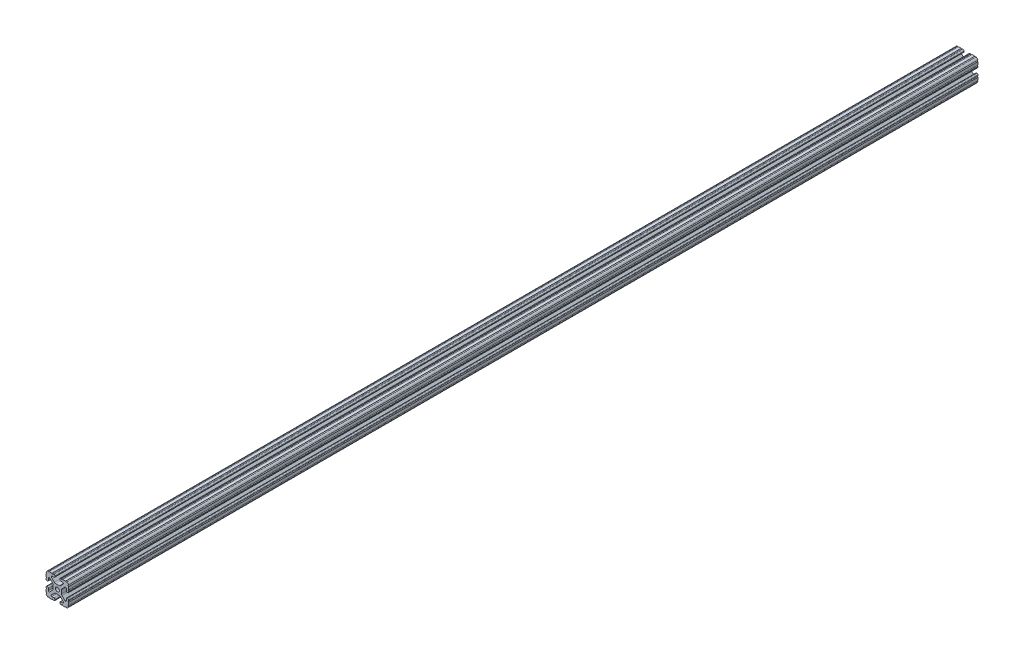
from build123d import *

# Parameters (mm, degrees)
BOSS_EXTRUDE1_DEPTH     = 762
SKETCH5_R               = 1.016
CUT_EXTRUDE1_DEPTH      = 763
CUT_EXTRUDE1_DEPTH_BACK = 763


with BuildPart() as part:
    # Sketch4 → Boss-Extrude1 (new body, symmetric)
    with BuildSketch(Plane.XY):
        with BuildLine():
            Line((5.7912, -19.05), (14.3002, -19.05))
            ThreePointArc((14.3002, -19.05), (17.658815789, -17.658815789), (19.05, -14.3002))
            Line((19.05, -14.3002), (19.05, -5.7912))
            ThreePointArc((19.05, -5.7912), (18.544114832, -4.569885168), (17.3228, -4.064))
            Line((17.3228, -4.064), (16.7132, -4.064))
            ThreePointArc((16.7132, -4.064), (15.491885168, -4.569885168), (14.986, -5.7912))
            Line((14.986, -5.7912), (14.986, -8.996305235))
            ThreePointArc((14.986, -8.996305235), (14.189232738, -10.188751711), (12.782646215, -9.908964256))
            Line((12.782646215, -9.908964256), (7.888897763, -5.015215804))
            ThreePointArc((7.888897763, -5.015215804), (7.219915375, -4.014012907), (6.985, -2.833013566))
            Line((6.985, -2.833013566), (6.985, 0))
            Line((6.985, 0), (3.3274, 0))
            ThreePointArc((3.3274, 0), (2.352827104, -2.352827104), (0, -3.3274))
            Line((0, -3.3274), (0, -6.985))
            Line((0, -6.985), (2.833013566, -6.985))
            ThreePointArc((2.833013566, -6.985), (4.014012907, -7.219915375), (5.015215804, -7.888897763))
            Line((5.015215804, -7.888897763), (9.908964256, -12.782646215))
            ThreePointArc((9.908964256, -12.782646215), (10.188751711, -14.189232738), (8.996305235, -14.986))
            Line((8.996305235, -14.986), (5.7912, -14.986))
            ThreePointArc((5.7912, -14.986), (4.569885168, -15.491885168), (4.064, -16.7132))
            Line((4.064, -16.7132), (4.064, -17.3228))
            ThreePointArc((4.064, -17.3228), (4.569885168, -18.544114832), (5.7912, -19.05))
        make_face()
    extrude(amount=BOSS_EXTRUDE1_DEPTH, both=True)

    # Sketch5 → Cut-Extrude1 (cut, two sides)
    with BuildSketch(Plane.XY) as cut_extrude1_sk:
        with Locations((14.739477062, -19.05)):
            Circle(SKETCH5_R)
        with Locations((7.980305235, -19.05)):
            Circle(SKETCH5_R)
        with Locations((19.05, -14.739477062)):
            Circle(SKETCH5_R)
        with Locations((19.05, -7.980305235)):
            Circle(SKETCH5_R)
    extrude(amount=CUT_EXTRUDE1_DEPTH, mode=Mode.SUBTRACT)
    extrude(cut_extrude1_sk.sketch, amount=-CUT_EXTRUDE1_DEPTH_BACK, mode=Mode.SUBTRACT)

    # Mirror1: part across plane


with BuildPart() as part_1:
    add(part.part)
    add(part.part.mirror(Plane(origin=(0, 0, 0), x_dir=(0, 0, 1), z_dir=(1, 0, 0))))

    # Mirror2: part across plane


with BuildPart() as part_2:
    add(part_1.part)
    add(part_1.part.mirror(Plane.ZX))


solid = part_2.part
